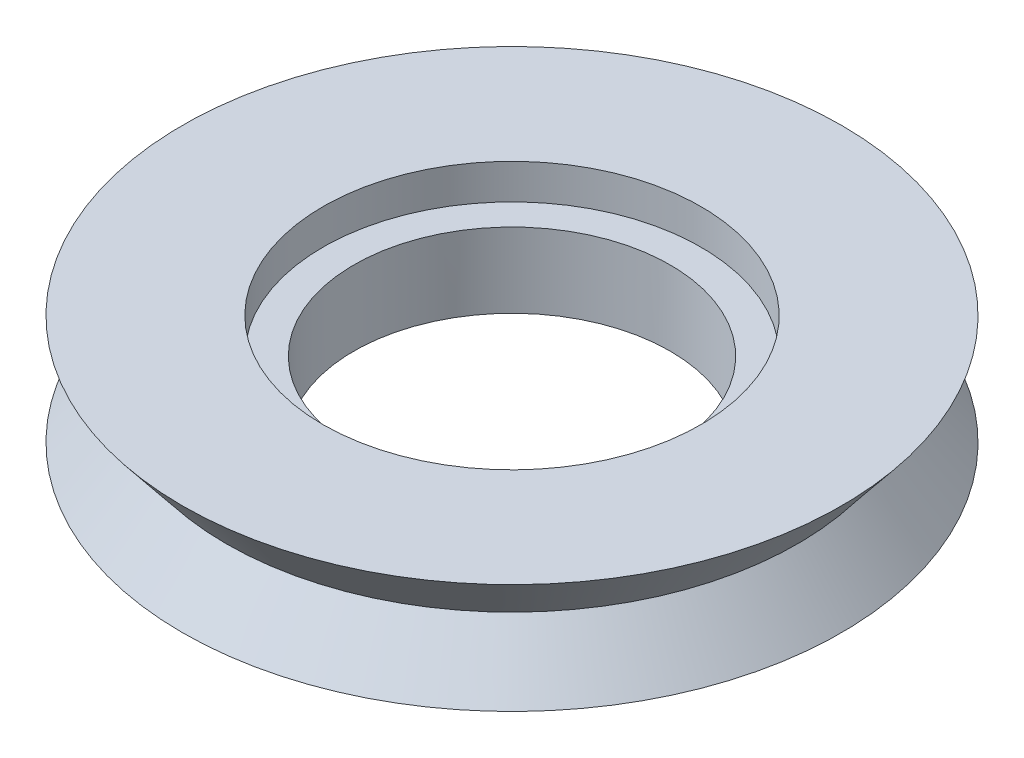
from build123d import *

# Parameters (mm, degrees)
SKETCH_2_R          = 2
CUT_EXTRUDE_1_DEPTH = 2.5
SKETCH_3_R          = 3.6
CUT_EXTRUDE_2_DEPTH = 2.5
SKETCH_4_R          = 4.3
CUT_EXTRUDE_3_DEPTH = 0.8


with BuildPart() as part:
    # 스케치1 → 회전1 (revolve)
    with BuildSketch(Plane.XY):
        Polygon((0, 0), (0, 2.5), (-7.5, 2.5), (-6.5, 1.25), (-7.5, 0), align=None)
    revolve(axis=Axis((0, 2.5, 0), (0, -1, 0)))

    # 스케치2 → 컷-돌출1 (cut)
    with BuildSketch(Plane(origin=(0, 2.5, 0), x_dir=(1, 0, 0), z_dir=(0, 1, 0))):
        Circle(SKETCH_2_R)
    extrude(amount=-CUT_EXTRUDE_1_DEPTH, mode=Mode.SUBTRACT)

    # 스케치3 → 컷-돌출2 (cut)
    with BuildSketch(Plane(origin=(0, 2.5, 0), x_dir=(1, 0, 0), z_dir=(0, 1, 0))):
        Circle(SKETCH_3_R)
    extrude(amount=-CUT_EXTRUDE_2_DEPTH, mode=Mode.SUBTRACT)

    # 스케치4 → 컷-돌출3 (cut)
    with BuildSketch(Plane(origin=(0, 2.5, 0), x_dir=(1, 0, 0), z_dir=(0, 1, 0))):
        Circle(SKETCH_4_R)
    extrude(amount=-CUT_EXTRUDE_3_DEPTH, mode=Mode.SUBTRACT)


solid = part.part
